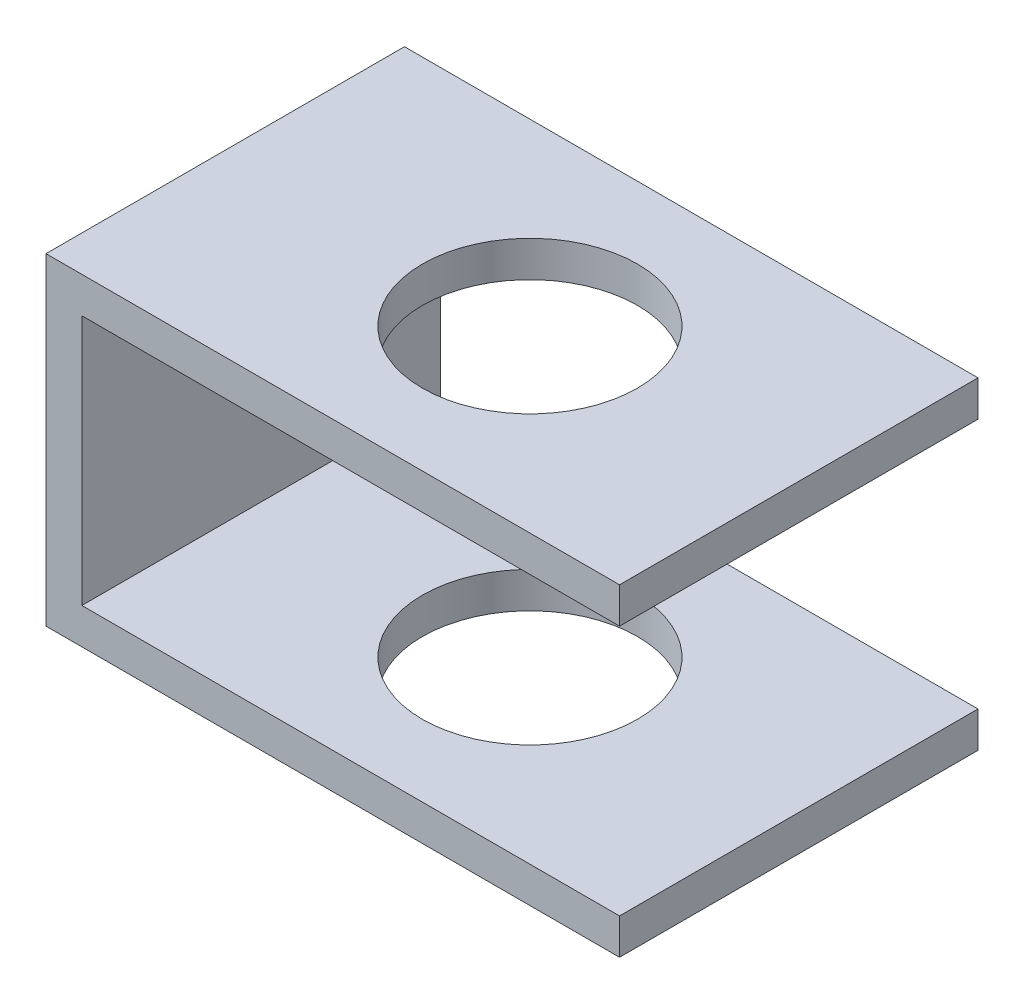
from build123d import *

# Parameters (mm, degrees)
SKETCH4_W           = 1.6
SKETCH4_H           = 0.9
BOSS_EXTRUDE3_DEPTH = 1
SKETCH6_R           = 0.3
CUT_EXTRUDE2_DEPTH  = 1
SKETCH7_W           = 1
SKETCH7_H           = 0.7
CUT_EXTRUDE3_DEPTH  = 1.5


with BuildPart() as part:
    # Sketch4 → Boss-Extrude3 (new body)
    with BuildSketch(Plane.XY):
        with Locations((0.8, -0.45)):
            Rectangle(SKETCH4_W, SKETCH4_H)
    extrude(amount=BOSS_EXTRUDE3_DEPTH)

    # Sketch6 → Cut-Extrude2 (cut)
    with BuildSketch(Plane(origin=(0, 0, 0), x_dir=(1, 0, 0), z_dir=(0, 1, 0))):
        with Locations((0.85, -0.5)):
            Circle(SKETCH6_R)
    extrude(amount=-CUT_EXTRUDE2_DEPTH, mode=Mode.SUBTRACT)

    # Sketch7 → Cut-Extrude3 (cut)
    with BuildSketch(Plane(origin=(1.6, 0, 0), x_dir=(0, 0, -1), z_dir=(1, 0, 0))):
        with Locations((-0.5, -0.45)):
            Rectangle(SKETCH7_W, SKETCH7_H)
    extrude(amount=-CUT_EXTRUDE3_DEPTH, mode=Mode.SUBTRACT)


solid = part.part
